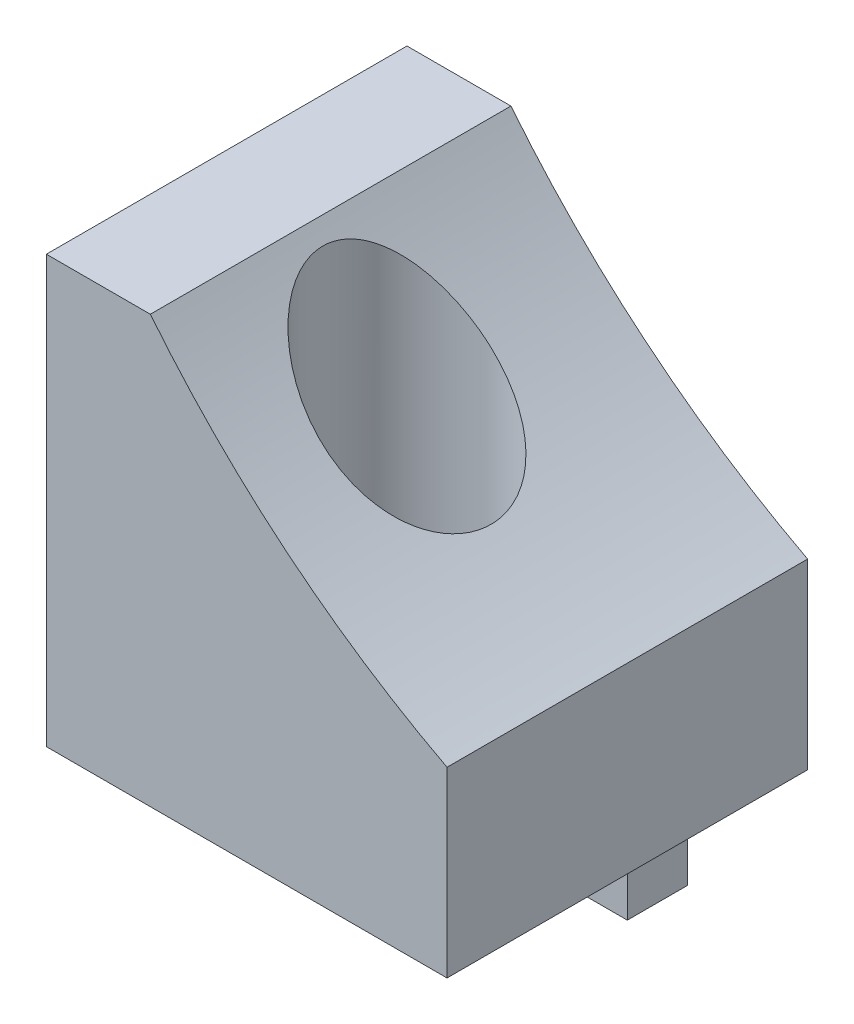
from build123d import *

# Parameters (mm, degrees)
EXTRUDE_1_DEPTH     = 18
SKETCH_2_R          = 4.2
CUT_EXTRUDE_1_DEPTH = 28
EXTRUDE_2_DEPTH     = 8
SKETCH_4_R          = 1.6
CUT_EXTRUDE_2_DEPTH = 8
CHAMFER_1_SIZE      = 5
CHAMFER_2_SIZE      = 5


with BuildPart() as part:
    # 草图1 → 凸台-拉伸1 (new body)
    with BuildSketch(Plane.XY):
        with BuildLine():
            Line((0, 0), (20, 0))
            Line((20, 0), (20, 9.111319982))
            ThreePointArc((20, 9.111319982), (11.967350423, 14.437400737), (5.19, 21.29))
            Line((5.19, 21.29), (0, 21.29))
            Line((0, 21.29), (0, 0))
        make_face()
    extrude(amount=EXTRUDE_1_DEPTH)

    # 草图2 → 切除-拉伸1 (cut)
    with BuildSketch(Plane.XZ):
        with Locations((10, 10)):
            Circle(SKETCH_2_R)
    extrude(amount=-CUT_EXTRUDE_1_DEPTH, mode=Mode.SUBTRACT)

    # 草图3 → 凸台-拉伸2 (add)
    with BuildSketch(Plane.XZ):
        Polygon((10, 0), (14, 0), (14, 3), (6, 3), (6, 0), align=None)
    extrude(amount=EXTRUDE_2_DEPTH)

    # 草图4 → 切除-拉伸2 (cut)
    with BuildSketch(Plane.XY.offset(3)):
        with Locations((10, -3)):
            Circle(SKETCH_4_R)
    extrude(amount=-CUT_EXTRUDE_2_DEPTH, mode=Mode.SUBTRACT)

    # 倒角1
    chamfer_1_edges = [part.edges().sort_by_distance(p)[0] for p in [
        (6, 0, 1.5),
    ]]
    chamfer(chamfer_1_edges, length=CHAMFER_1_SIZE)

    # 倒角2
    chamfer_2_edges = [part.edges().sort_by_distance(p)[0] for p in [
        (14, 0, 1.5),
    ]]
    chamfer(chamfer_2_edges, length=CHAMFER_2_SIZE)


solid = part.part
